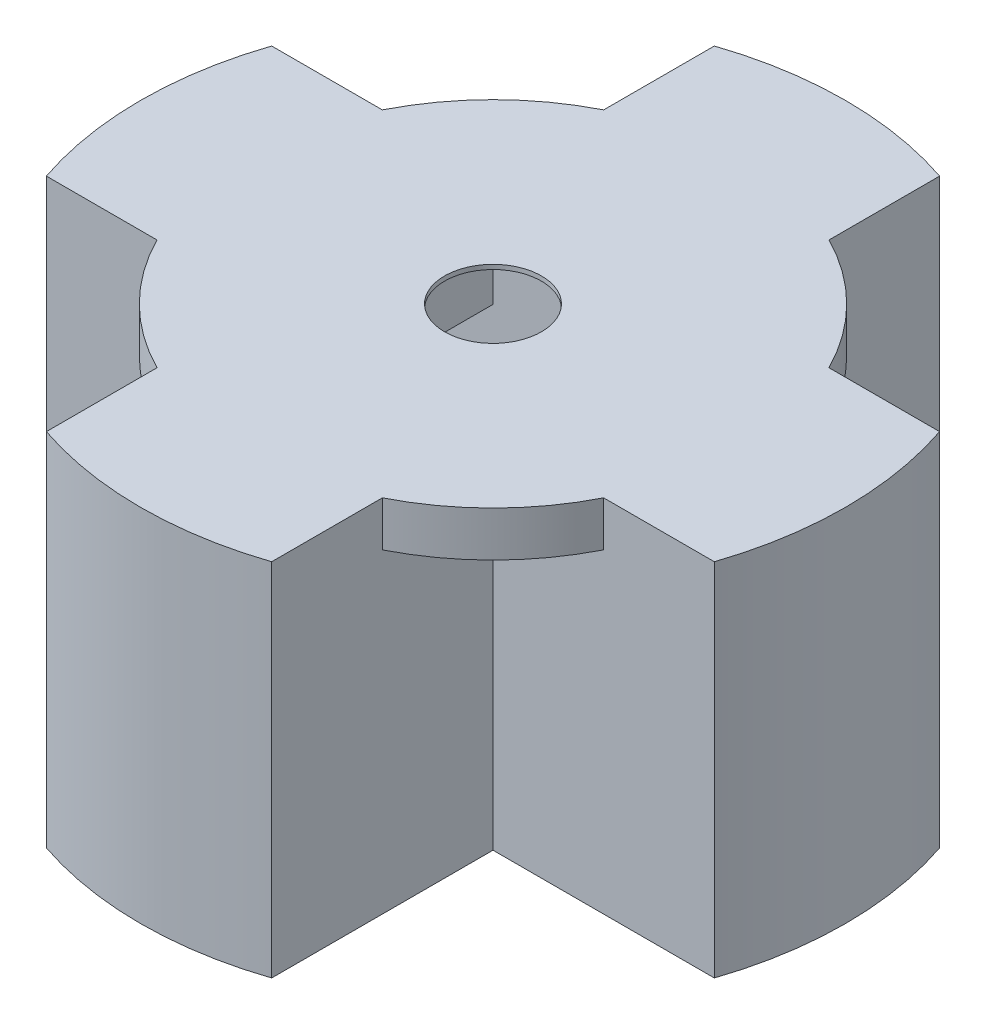
from build123d import *

# Parameters (mm, degrees)
SKETCH1_W           = 54.737
SKETCH1_H           = 25.4
SKETCH1_W_2         = 40.2717
SKETCH1_H_2         = 19.7104
BOSS_EXTRUDE2_DEPTH = 9.906
SKETCH3_R           = 9.8552
SKETCH3_R_2         = 5.461
BOSS_EXTRUDE3_DEPTH = 0.508
SKETCH9_W           = 7.23265
SKETCH9_H           = 1.27
CUT_EXTRUDE2_DEPTH  = 5.08
SKETCH12_W          = 54.737
SKETCH12_H          = 2.8448
BOSS_EXTRUDE4_DEPTH = 30.734
BOSS_EXTRUDE5_DEPTH = 20.5613
BOSS_EXTRUDE6_DEPTH = 24.94915
BOSS_EXTRUDE7_DEPTH = 24.94915
BOSS_EXTRUDE8_DEPTH = 40.64
BOSS_EXTRUDE9_DEPTH = 5.08
SKETCH25_W          = 2.54
SKETCH25_H          = 6.35
CUT_EXTRUDE3_DEPTH  = 2.54


with BuildPart() as part:
    # Sketch1 → Boss-Extrude2 (new body)
    with BuildSketch(Plane(origin=(0, 0, 0), x_dir=(1, 0, 0), z_dir=(0, 1, 0))):
        with Locations((-20.13585, -9.8552)):
            Rectangle(SKETCH1_W, SKETCH1_H)
        with Locations((-20.13585, -9.8552)):
            Rectangle(SKETCH1_W_2, SKETCH1_H_2, mode=Mode.SUBTRACT)
    extrude(amount=BOSS_EXTRUDE2_DEPTH)

    # Sketch3 → Boss-Extrude3 (add)
    with BuildSketch(Plane(origin=(0, 9.906, 0), x_dir=(1, 0, 0), z_dir=(0, 1, 0))):
        with Locations((-30.4165, -9.8552)):
            Circle(SKETCH3_R)
        with Locations((-30.4165, -9.8552)):
            Circle(SKETCH3_R_2, mode=Mode.SUBTRACT)
        with BuildLine():
            ThreePointArc((-30.4165, -19.7104), (-37.38517875, -16.82387875), (-40.2717, -9.8552))
            Line((-40.2717, -9.8552), (-40.2717, -19.7104))
            Line((-40.2717, -19.7104), (-30.4165, -19.7104))
        make_face()
        with BuildLine():
            Line((0, 0), (-30.4165, 0))
            ThreePointArc((-30.4165, 0), (-23.44782125, -2.88652125), (-20.5613, -9.8552))
            ThreePointArc((-20.5613, -9.8552), (-23.44782125, -16.82387875), (-30.4165, -19.7104))
            Line((-30.4165, -19.7104), (0, -19.7104))
            Line((0, -19.7104), (0, 0))
        make_face()
        with BuildLine():
            Line((-30.4165, 0), (-40.2717, 0))
            Line((-40.2717, 0), (-40.2717, -9.8552))
            ThreePointArc((-40.2717, -9.8552), (-37.38517875, -2.88652125), (-30.4165, 0))
        make_face()
    extrude(amount=-BOSS_EXTRUDE3_DEPTH)

    # Sketch9 → Cut-Extrude2 (cut)
    with BuildSketch(Plane.XZ):
        with Locations((-43.888025, 9.8552)):
            Rectangle(SKETCH9_W, SKETCH9_H)
        with Locations((3.616325, 9.8552)):
            Rectangle(SKETCH9_W, SKETCH9_H)
    extrude(amount=-CUT_EXTRUDE2_DEPTH, mode=Mode.SUBTRACT)

    # Sketch12 → Boss-Extrude4 (add)
    with BuildSketch(Plane.XZ):
        with Locations((-20.13585, 21.1328)):
            Rectangle(SKETCH12_W, SKETCH12_H)
        with Locations((-20.13585, -1.4224)):
            Rectangle(SKETCH12_W, SKETCH12_H)
    extrude(amount=BOSS_EXTRUDE4_DEPTH)

    # Sketch19 → Boss-Extrude5 (add)
    with BuildSketch(Plane.ZY.offset(47.50435)):
        Polygon((-2.8448, -30.734), (0, -30.734), (0, 0), (19.7104, 0), (19.7104, -30.734), (22.5552, -30.734), (22.5552, 9.906), (-2.8448, 9.906), align=None)
    extrude(amount=BOSS_EXTRUDE5_DEPTH)

    # Sketch20 → Boss-Extrude6 (add)
    with BuildSketch(Plane(origin=(0, 0, -2.8448), x_dir=(-1, 0, 0), z_dir=(0, 0, -1))):
        Polygon((17.7165, 9.906), (43.1165, 9.906), (43.1165, -30.734), (40.3225, -30.734), (40.3225, 0), (20.5105, 0), (20.5105, -30.734), (17.7165, -30.734), align=None)
    extrude(amount=BOSS_EXTRUDE6_DEPTH)

    # Sketch21 → Boss-Extrude7 (add)
    with BuildSketch(Plane.XY.offset(22.5552)):
        Polygon((-43.1165, 9.906), (-43.1165, -30.734), (-40.3225, -30.734), (-40.3225, 0), (-20.5105, 0), (-20.5105, -30.734), (-17.7165, -30.734), (-17.7165, 9.906), align=None)
    extrude(amount=BOSS_EXTRUDE7_DEPTH)

    # Sketch23 → Boss-Extrude8 (add)
    with BuildSketch(Plane(origin=(0, 9.906, 0), x_dir=(1, 0, 0), z_dir=(0, 1, 0))):
        with BuildLine():
            Line((-68.06565, 2.8448), (-68.06565, -22.5552))
            ThreePointArc((-68.06565, -22.5552), (-70.149968207, -9.8552), (-68.06565, 2.8448))
        make_face()
        with BuildLine():
            Line((-43.1165, -47.50435), (-17.7165, -47.50435))
            ThreePointArc((-17.7165, -47.50435), (-30.4165, -49.588668207), (-43.1165, -47.50435))
        make_face()
        with BuildLine():
            Line((7.23265, -22.5552), (7.23265, 2.8448))
            ThreePointArc((7.23265, 2.8448), (9.316968207, -9.8552), (7.23265, -22.5552))
        make_face()
        with BuildLine():
            Line((-17.7165, 27.79395), (-43.1165, 27.79395))
            ThreePointArc((-43.1165, 27.79395), (-30.4165, 29.878268207), (-17.7165, 27.79395))
        make_face()
    extrude(amount=-BOSS_EXTRUDE8_DEPTH)

    # Sketch24 → Boss-Extrude9 (add)
    with BuildSketch(Plane(origin=(0, 9.906, 0), x_dir=(1, 0, 0), z_dir=(0, 1, 0))):
        with BuildLine():
            ThreePointArc((-43.1165, 15.319375), (-50.35451929, 10.08281929), (-55.591075, 2.8448))
            Line((-55.591075, 2.8448), (-43.1165, 2.8448))
            Line((-43.1165, 2.8448), (-43.1165, 15.319375))
        make_face()
        with BuildLine():
            ThreePointArc((-55.591075, -22.5552), (-50.35451929, -29.79321929), (-43.1165, -35.029775))
            Line((-43.1165, -35.029775), (-43.1165, -22.5552))
            Line((-43.1165, -22.5552), (-55.591075, -22.5552))
        make_face()
        with BuildLine():
            ThreePointArc((-17.7165, -35.029775), (-10.47848071, -29.79321929), (-5.241925, -22.5552))
            Line((-5.241925, -22.5552), (-17.7165, -22.5552))
            Line((-17.7165, -22.5552), (-17.7165, -35.029775))
        make_face()
        with BuildLine():
            ThreePointArc((-5.241925, 2.8448), (-10.47848071, 10.08281929), (-17.7165, 15.319375))
            Line((-17.7165, 15.319375), (-17.7165, 2.8448))
            Line((-17.7165, 2.8448), (-5.241925, 2.8448))
        make_face()
    extrude(amount=-BOSS_EXTRUDE9_DEPTH)

    # Sketch25 → Cut-Extrude3 (cut)
    with BuildSketch(Plane.XZ.offset(30.734)):
        with Locations((-69.33565, 9.8552)):
            Rectangle(SKETCH25_W, SKETCH25_H)
    extrude(amount=-CUT_EXTRUDE3_DEPTH, mode=Mode.SUBTRACT)


solid = part.part
